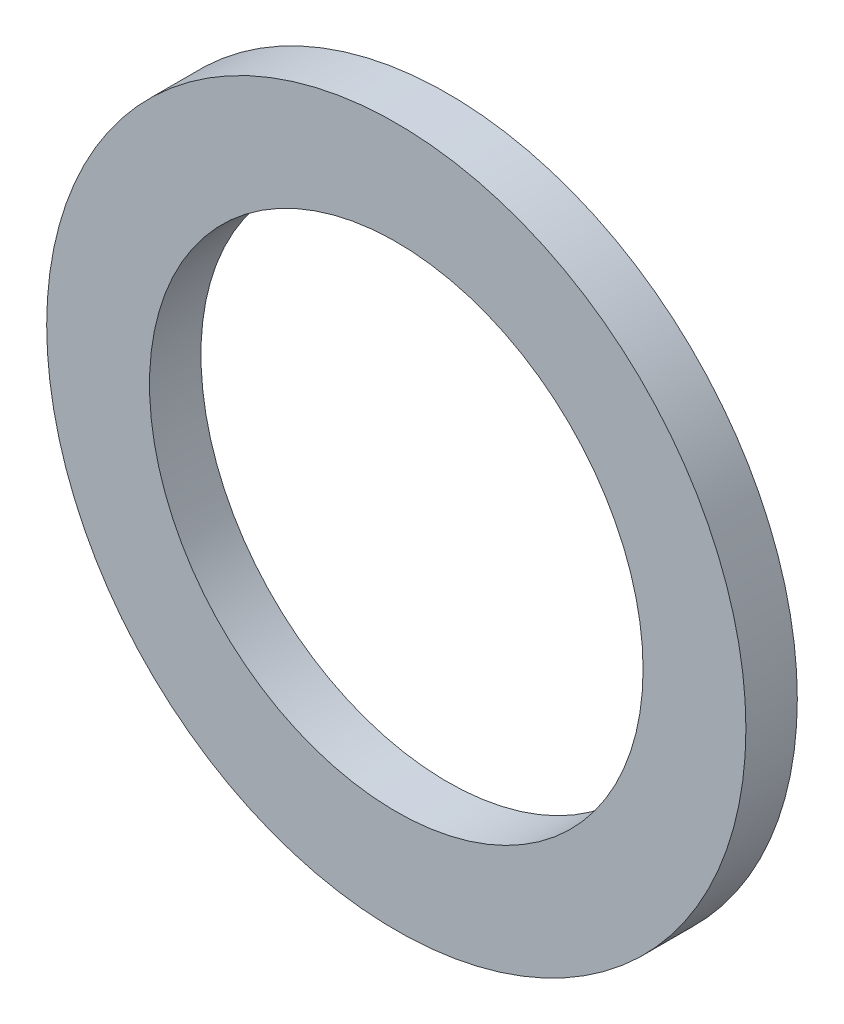
from build123d import *

# Parameters (mm, degrees)
SKETCH1_R           = 21.59
SKETCH1_R_2         = 15.24
BOSS_EXTRUDE1_DEPTH = 3.175


with BuildPart() as part:
    # Sketch1 → Boss-Extrude1 (new body)
    with BuildSketch(Plane.XY):
        Circle(SKETCH1_R)
        Circle(SKETCH1_R_2, mode=Mode.SUBTRACT)
    extrude(amount=BOSS_EXTRUDE1_DEPTH)


solid = part.part
